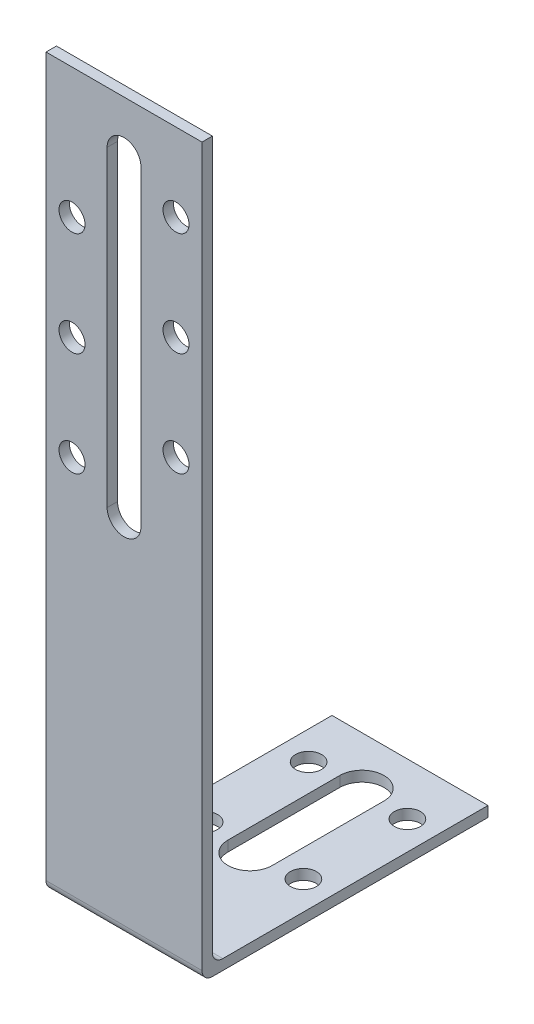
from build123d import *

# Parameters (mm, degrees)
BOSS_EXTRU_1_DEPTH      = 15
CONG_1_R                = 2
ENL_V_MAT_EXTRU_1_REACH = 4
ESQUISSE2_R             = 2.5
ENL_V_MAT_EXTRU_2_REACH = 4
ESQUISSE4_R             = 2.5


with BuildPart() as part:
    # Esquisse1 → Boss.-Extru.1 (new body, symmetric)
    with BuildSketch(Plane(origin=(0, 0, 0), x_dir=(0, 0, -1), z_dir=(1, 0, 0))):
        Polygon((0, 0), (0, 140), (2, 140), (2, 2), (55, 2), (55, 0), align=None)
    extrude(amount=BOSS_EXTRU_1_DEPTH, both=True)

    # Congé1
    cong_1_edges = [part.edges().sort_by_distance(p)[0] for p in [
        (0, 0, 0),
        (0, 2, -2),
    ]]
    fillet(cong_1_edges, radius=CONG_1_R)

    # Esquisse2 → Enlèv. mat.-Extru.1 (cut, up to next)
    with BuildSketch(Plane(origin=(0, 2, 0), x_dir=(1, 0, 0), z_dir=(0, 1, 0)), mode=Mode.PRIVATE) as enl_v_mat_extru_1_sk1:
        with BuildLine():
            Line((4.25, 24.25), (4.25, 45.75))
            ThreePointArc((4.25, 45.75), (0, 50), (-4.25, 45.75))
            Line((-4.25, 45.75), (-4.25, 24.25))
            ThreePointArc((-4.25, 24.25), (0, 20), (4.25, 24.25))
        make_face()
    enl_v_mat_extru_1_tool1 = extrude(enl_v_mat_extru_1_sk1.sketch, amount=-ENL_V_MAT_EXTRU_1_REACH, mode=Mode.PRIVATE) & part.part
    add(enl_v_mat_extru_1_tool1.solids().sort_by_distance((0, 2, -35))[0], mode=Mode.SUBTRACT)
    # Esquisse2 → Enlèv. mat.-Extru.1 (cut, up to next)
    with BuildSketch(Plane(origin=(0, 2, 0), x_dir=(1, 0, 0), z_dir=(0, 1, 0)), mode=Mode.PRIVATE) as enl_v_mat_extru_1_sk2:
        with Locations((-9.5, 25)):
            Circle(ESQUISSE2_R)
    enl_v_mat_extru_1_tool2 = extrude(enl_v_mat_extru_1_sk2.sketch, amount=-ENL_V_MAT_EXTRU_1_REACH, mode=Mode.PRIVATE) & part.part
    add(enl_v_mat_extru_1_tool2.solids().sort_by_distance((-9.5, 2, -25))[0], mode=Mode.SUBTRACT)
    # Esquisse2 → Enlèv. mat.-Extru.1 (cut, up to next)
    with BuildSketch(Plane(origin=(0, 2, 0), x_dir=(1, 0, 0), z_dir=(0, 1, 0)), mode=Mode.PRIVATE) as enl_v_mat_extru_1_sk3:
        with Locations((-9.5, 45)):
            Circle(ESQUISSE2_R)
    enl_v_mat_extru_1_tool3 = extrude(enl_v_mat_extru_1_sk3.sketch, amount=-ENL_V_MAT_EXTRU_1_REACH, mode=Mode.PRIVATE) & part.part
    add(enl_v_mat_extru_1_tool3.solids().sort_by_distance((-9.5, 2, -45))[0], mode=Mode.SUBTRACT)
    # Esquisse2 → Enlèv. mat.-Extru.1 (cut, up to next)
    with BuildSketch(Plane(origin=(0, 2, 0), x_dir=(1, 0, 0), z_dir=(0, 1, 0)), mode=Mode.PRIVATE) as enl_v_mat_extru_1_sk4:
        with Locations((9.5, 45)):
            Circle(ESQUISSE2_R)
    enl_v_mat_extru_1_tool4 = extrude(enl_v_mat_extru_1_sk4.sketch, amount=-ENL_V_MAT_EXTRU_1_REACH, mode=Mode.PRIVATE) & part.part
    add(enl_v_mat_extru_1_tool4.solids().sort_by_distance((9.5, 2, -45))[0], mode=Mode.SUBTRACT)
    # Esquisse2 → Enlèv. mat.-Extru.1 (cut, up to next)
    with BuildSketch(Plane(origin=(0, 2, 0), x_dir=(1, 0, 0), z_dir=(0, 1, 0)), mode=Mode.PRIVATE) as enl_v_mat_extru_1_sk5:
        with Locations((9.5, 25)):
            Circle(ESQUISSE2_R)
    enl_v_mat_extru_1_tool5 = extrude(enl_v_mat_extru_1_sk5.sketch, amount=-ENL_V_MAT_EXTRU_1_REACH, mode=Mode.PRIVATE) & part.part
    add(enl_v_mat_extru_1_tool5.solids().sort_by_distance((9.5, 2, -25))[0], mode=Mode.SUBTRACT)

    # Esquisse4 → Enlèv. mat.-Extru.2 (cut, up to next)
    with BuildSketch(Plane(origin=(0, 0, -2), x_dir=(-1, 0, 0), z_dir=(0, 0, -1)), mode=Mode.PRIVATE) as enl_v_mat_extru_2_sk1:
        with Locations((-10, 125)):
            Circle(ESQUISSE4_R)
    enl_v_mat_extru_2_tool1 = extrude(enl_v_mat_extru_2_sk1.sketch, amount=-ENL_V_MAT_EXTRU_2_REACH, mode=Mode.PRIVATE) & part.part
    add(enl_v_mat_extru_2_tool1.solids().sort_by_distance((10, 125, -2))[0], mode=Mode.SUBTRACT)
    # Esquisse4 → Enlèv. mat.-Extru.2 (cut, up to next)
    with BuildSketch(Plane(origin=(0, 0, -2), x_dir=(-1, 0, 0), z_dir=(0, 0, -1)), mode=Mode.PRIVATE) as enl_v_mat_extru_2_sk2:
        with Locations((-10, 105)):
            Circle(ESQUISSE4_R)
    enl_v_mat_extru_2_tool2 = extrude(enl_v_mat_extru_2_sk2.sketch, amount=-ENL_V_MAT_EXTRU_2_REACH, mode=Mode.PRIVATE) & part.part
    add(enl_v_mat_extru_2_tool2.solids().sort_by_distance((10, 105, -2))[0], mode=Mode.SUBTRACT)
    # Esquisse4 → Enlèv. mat.-Extru.2 (cut, up to next)
    with BuildSketch(Plane(origin=(0, 0, -2), x_dir=(-1, 0, 0), z_dir=(0, 0, -1)), mode=Mode.PRIVATE) as enl_v_mat_extru_2_sk3:
        with Locations((-10, 85)):
            Circle(ESQUISSE4_R)
    enl_v_mat_extru_2_tool3 = extrude(enl_v_mat_extru_2_sk3.sketch, amount=-ENL_V_MAT_EXTRU_2_REACH, mode=Mode.PRIVATE) & part.part
    add(enl_v_mat_extru_2_tool3.solids().sort_by_distance((10, 85, -2))[0], mode=Mode.SUBTRACT)
    # Esquisse4 → Enlèv. mat.-Extru.2 (cut, up to next)
    with BuildSketch(Plane(origin=(0, 0, -2), x_dir=(-1, 0, 0), z_dir=(0, 0, -1)), mode=Mode.PRIVATE) as enl_v_mat_extru_2_sk4:
        with Locations((10, 115)):
            Circle(ESQUISSE4_R)
    enl_v_mat_extru_2_tool4 = extrude(enl_v_mat_extru_2_sk4.sketch, amount=-ENL_V_MAT_EXTRU_2_REACH, mode=Mode.PRIVATE) & part.part
    add(enl_v_mat_extru_2_tool4.solids().sort_by_distance((-10, 115, -2))[0], mode=Mode.SUBTRACT)
    # Esquisse4 → Enlèv. mat.-Extru.2 (cut, up to next)
    with BuildSketch(Plane(origin=(0, 0, -2), x_dir=(-1, 0, 0), z_dir=(0, 0, -1)), mode=Mode.PRIVATE) as enl_v_mat_extru_2_sk5:
        with Locations((10, 95)):
            Circle(ESQUISSE4_R)
    enl_v_mat_extru_2_tool5 = extrude(enl_v_mat_extru_2_sk5.sketch, amount=-ENL_V_MAT_EXTRU_2_REACH, mode=Mode.PRIVATE) & part.part
    add(enl_v_mat_extru_2_tool5.solids().sort_by_distance((-10, 95, -2))[0], mode=Mode.SUBTRACT)
    # Esquisse4 → Enlèv. mat.-Extru.2 (cut, up to next)
    with BuildSketch(Plane(origin=(0, 0, -2), x_dir=(-1, 0, 0), z_dir=(0, 0, -1)), mode=Mode.PRIVATE) as enl_v_mat_extru_2_sk6:
        with Locations((10, 75)):
            Circle(ESQUISSE4_R)
    enl_v_mat_extru_2_tool6 = extrude(enl_v_mat_extru_2_sk6.sketch, amount=-ENL_V_MAT_EXTRU_2_REACH, mode=Mode.PRIVATE) & part.part
    add(enl_v_mat_extru_2_tool6.solids().sort_by_distance((-10, 75, -2))[0], mode=Mode.SUBTRACT)
    # Esquisse4 → Enlèv. mat.-Extru.2 (cut, up to next)
    with BuildSketch(Plane(origin=(0, 0, -2), x_dir=(-1, 0, 0), z_dir=(0, 0, -1)), mode=Mode.PRIVATE) as enl_v_mat_extru_2_sk7:
        with BuildLine():
            Line((3.25, 130), (3.25, 70))
            ThreePointArc((3.25, 70), (0, 66.75), (-3.25, 70))
            Line((-3.25, 70), (-3.25, 130))
            ThreePointArc((-3.25, 130), (0, 133.25), (3.25, 130))
        make_face()
    enl_v_mat_extru_2_tool7 = extrude(enl_v_mat_extru_2_sk7.sketch, amount=-ENL_V_MAT_EXTRU_2_REACH, mode=Mode.PRIVATE) & part.part
    add(enl_v_mat_extru_2_tool7.solids().sort_by_distance((0, 100, -2))[0], mode=Mode.SUBTRACT)


solid = part.part
